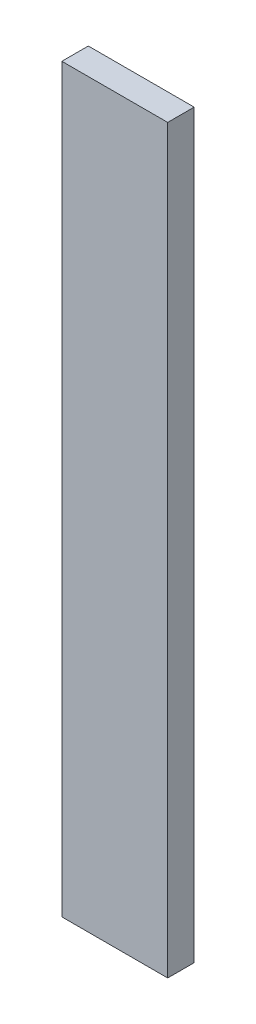
from build123d import *

# Parameters (mm, degrees)
SKETCH1_W           = 25.4
SKETCH1_H           = 177.8
BOSS_EXTRUDE1_DEPTH = 6.35


with BuildPart() as part:
    # Sketch1 → Boss-Extrude1 (new body)
    with BuildSketch(Plane.XY):
        Rectangle(SKETCH1_W, SKETCH1_H)
    extrude(amount=BOSS_EXTRUDE1_DEPTH)


solid = part.part
